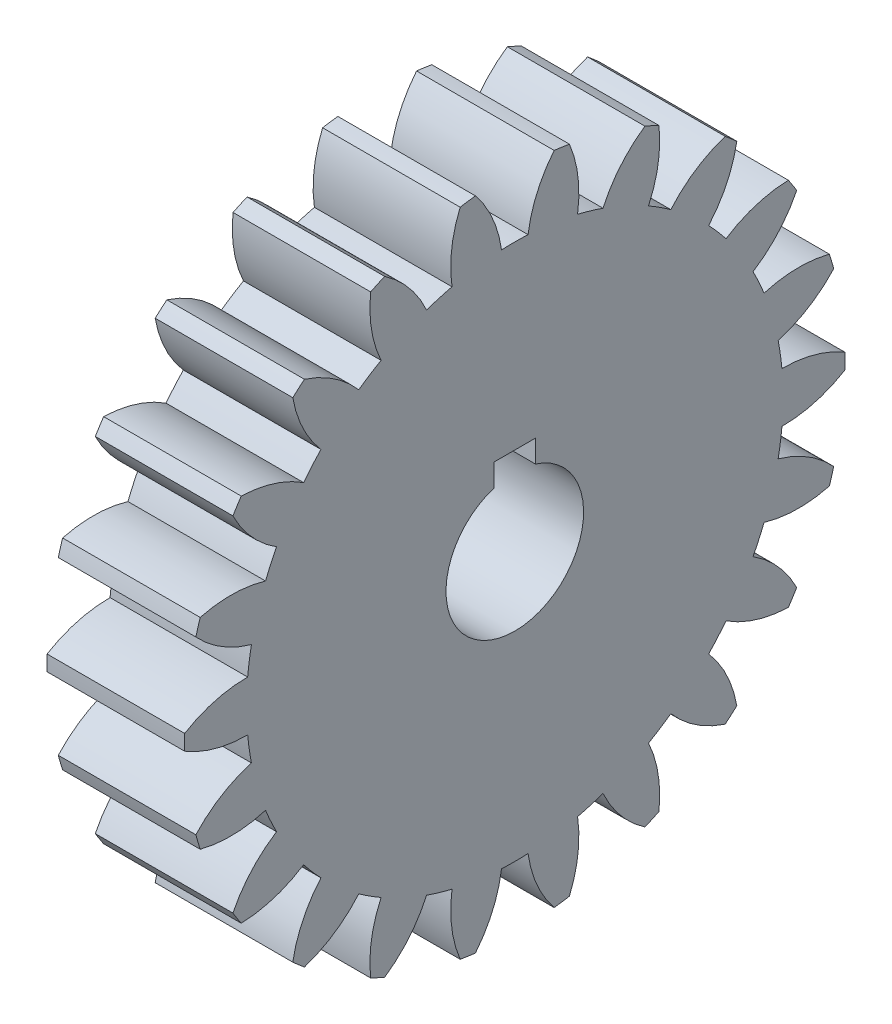
from build123d import *

# Parameters (mm, degrees)
BASPROSKE_W     = 20
BASPROSKE_H     = 48
TOOTHCUT_DEPTH  = 71.767224052
TEETHCUTS_COUNT = 22
TEETHCUTS_ANGLE = 343.636363636
BORSKE_R        = 10
BORE_DEPTH      = 50.0000508
KEYSKE_W        = 6
KEYSKE_H        = 12.8
KEYWAY_DEPTH    = 50.0000508


with BuildPart() as part:
    # BasProSke → Base-Revolve (revolve)
    with BuildSketch(Plane(origin=(0, 0, 0), x_dir=(1, 0, 0), z_dir=(0, 1, 0)), mode=Mode.PRIVATE) as base_revolve_sk:
        with Locations((10, 24)):
            Rectangle(BASPROSKE_W, BASPROSKE_H)
    revolve(base_revolve_sk.sketch.rotate(Axis((-10, 0, 0), (1, 0, 0)), 180), axis=Axis((-10, 0, 0), (1, 0, 0)))

    # TooCutSke → ToothCut (cut, through all)
    with BuildSketch(Plane(origin=(0, 0, 0), x_dir=(0, 0, -1), z_dir=(1, 0, 0))):
        with BuildLine():
            ThreePointArc((1.925610671, 38.951431611), (0, 38.999), (-1.925610671, 38.951431611))
            ThreePointArc((-1.925610671, 38.951431611), (-3.230295596, 43.579258947), (-5.738738554, 47.681295337))
            ThreePointArc((-5.738738554, 47.681295337), (0, 48.0254), (5.738738554, 47.681295337))
            ThreePointArc((5.738738554, 47.681295337), (3.230295596, 43.579258947), (1.925610671, 38.951431611))
        make_face()
    toothcut = extrude(amount=TOOTHCUT_DEPTH, mode=Mode.SUBTRACT)

    # TeethCuts: ToothCut ×22 about axis
    teethcuts_axis = Axis((-10, 0, 0), (1, 0, 0))
    for i in range(1, TEETHCUTS_COUNT):
        add(toothcut.rotate(teethcuts_axis, i * TEETHCUTS_ANGLE / (TEETHCUTS_COUNT - 1)), mode=Mode.SUBTRACT)

    # BorSke → Bore (cut, symmetric)
    with BuildSketch(Plane(origin=(0, 0, 0), x_dir=(0, 0, -1), z_dir=(1, 0, 0))):
        with Locations(Location((0, 0, 0), (0, 0, 180))):
            Circle(BORSKE_R)
    extrude(amount=BORE_DEPTH, both=True, mode=Mode.SUBTRACT)

    # KeySke → Keyway (cut, symmetric)
    with BuildSketch(Plane(origin=(0, 0, 0), x_dir=(0, 0, -1), z_dir=(1, 0, 0))):
        with Locations((0, 6.4)):
            Rectangle(KEYSKE_W, KEYSKE_H)
    extrude(amount=KEYWAY_DEPTH, both=True, mode=Mode.SUBTRACT)


solid = part.part
